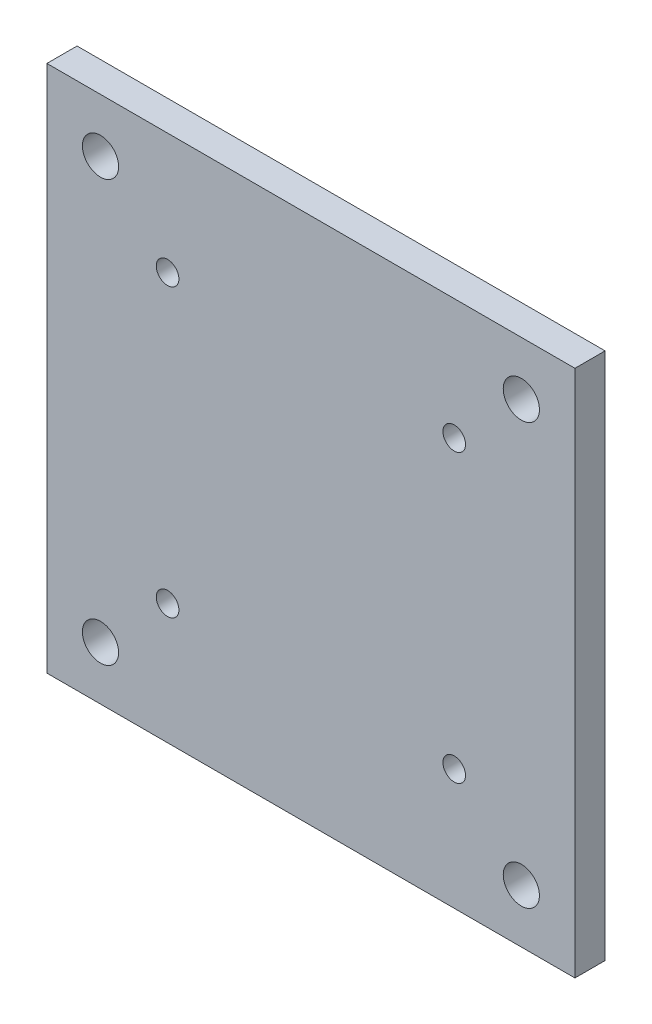
from build123d import *

# Parameters (mm, degrees)
SKETCH1_W           = 70
SKETCH1_H           = 70
SKETCH1_R           = 2.4
SKETCH1_R_2         = 1.5
BOSS_EXTRUDE2_DEPTH = 4


with BuildPart() as part:
    # Sketch1 → Boss-Extrude2 (new body)
    with BuildSketch(Plane.XY):
        with Locations((0, 35)):
            Rectangle(SKETCH1_W, SKETCH1_H)
        with Locations((-27.895, 7.105)):
            Circle(SKETCH1_R, mode=Mode.SUBTRACT)
        with Locations((-27.895, 62.895)):
            Circle(SKETCH1_R, mode=Mode.SUBTRACT)
        with Locations((19, 54)):
            Circle(SKETCH1_R_2, mode=Mode.SUBTRACT)
        with Locations((19, 16)):
            Circle(SKETCH1_R_2, mode=Mode.SUBTRACT)
        with Locations((-19, 16)):
            Circle(SKETCH1_R_2, mode=Mode.SUBTRACT)
        with Locations((27.895, 62.895)):
            Circle(SKETCH1_R, mode=Mode.SUBTRACT)
        with Locations((27.895, 7.105)):
            Circle(SKETCH1_R, mode=Mode.SUBTRACT)
        with Locations((-19, 54)):
            Circle(SKETCH1_R_2, mode=Mode.SUBTRACT)
    extrude(amount=BOSS_EXTRUDE2_DEPTH)


solid = part.part
